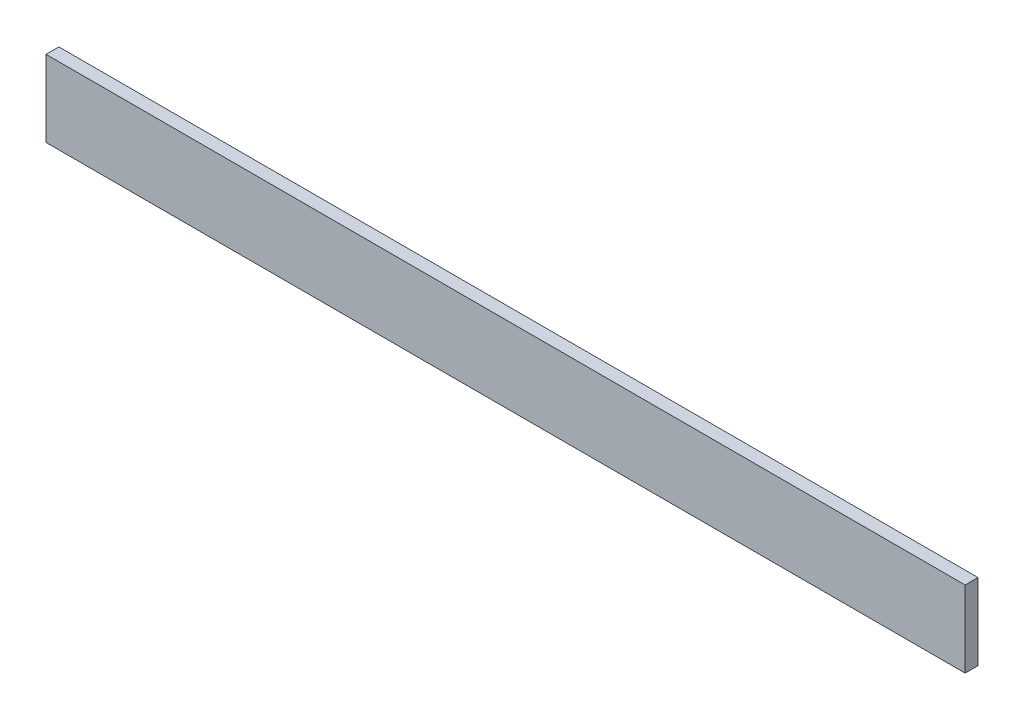
from build123d import *

# Parameters (mm, degrees)
SKETCH1_W           = 214.122
SKETCH1_H           = 17.78
BOSS_EXTRUDE1_DEPTH = 3


with BuildPart() as part:
    # Sketch1 → Boss-Extrude1 (new body)
    with BuildSketch(Plane.XY):
        Rectangle(SKETCH1_W, SKETCH1_H)
    extrude(amount=BOSS_EXTRUDE1_DEPTH)


solid = part.part
